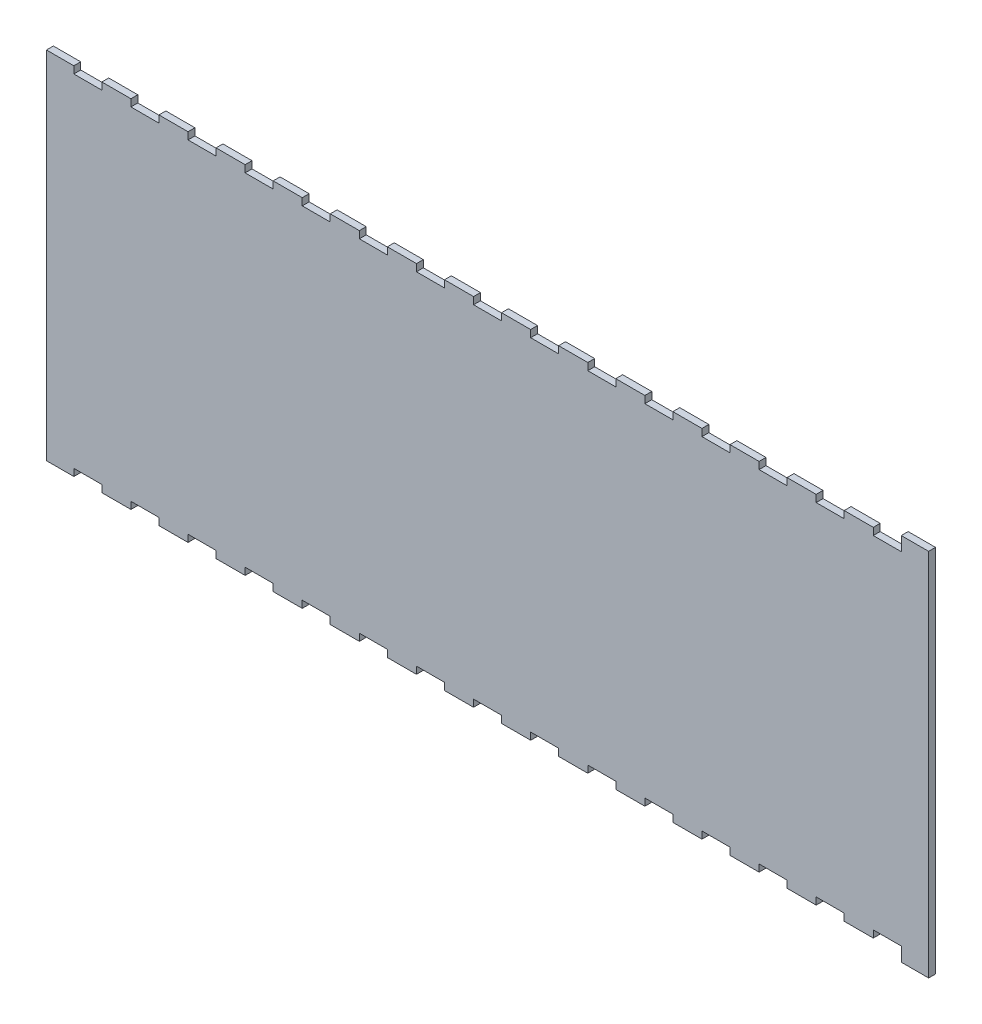
from build123d import *

# Parameters (mm, degrees)
BOSS_EXTRUDE1_DEPTH = 3.175


with BuildPart() as part:
    # Sketch1 → Boss-Extrude1 (new body)
    with BuildSketch(Plane.XY):
        Polygon((-12.6, 160.6058), (-25.5, 160.6058), (-25.5, 163.8808), (-38.907142857, 163.8808), (-38.907142857, 160.6058), (-51.807142857, 160.6058), (-51.807142857, 163.8808), (-65.214285714, 163.8808), (-65.214285714, 160.6058), (-78.114285714, 160.6058), (-78.114285714, 163.8808), (-91.521428571, 163.8808), (-91.521428571, 160.6058), (-104.421428571, 160.6058), (-104.421428571, 163.8808), (-117.828571429, 163.8808), (-117.828571429, 160.6058), (-130.728571429, 160.6058), (-130.728571429, 163.8808), (-144.135714286, 163.8808), (-144.135714286, 160.6058), (-157.035714286, 160.6058), (-157.035714286, 163.8808), (-170.442857143, 163.8808), (-170.442857143, 160.6058), (-183.342857143, 160.6058), (-183.342857143, 163.8808), (-196.75, 163.8808), (-196.75, 160.6058), (-209.65, 160.6058), (-209.65, 163.8808), (-223.057142857, 163.8808), (-223.057142857, 160.6058), (-235.957142857, 160.6058), (-235.957142857, 163.8808), (-249.364285714, 163.8808), (-249.364285714, 160.6058), (-262.264285714, 160.6058), (-262.264285714, 163.8808), (-275.671428571, 163.8808), (-275.671428571, 160.6058), (-288.571428571, 160.6058), (-288.571428571, 163.8808), (-301.978571429, 163.8808), (-301.978571429, 160.6058), (-314.878571429, 160.6058), (-314.878571429, 163.8808), (-328.285714286, 163.8808), (-328.285714286, 160.6058), (-341.185714286, 160.6058), (-341.185714286, 163.8808), (-354.592857143, 163.8808), (-354.592857143, 160.6058), (-367.492857143, 160.6058), (-367.492857143, 163.8808), (-380.9, 163.8808), (-380.9, 160.6058), (-393.8, 160.6058), (-393.8, 163.8808), (-406.4, 163.8808), (-406.4, 0), (-393.8, 0), (-393.8, 3.275), (-380.9, 3.275), (-380.9, 0), (-367.492857143, 0), (-367.492857143, 3.275), (-354.592857143, 3.275), (-354.592857143, 0), (-341.185714286, 0), (-341.185714286, 3.275), (-328.285714286, 3.275), (-328.285714286, 0), (-314.878571429, 0), (-314.878571429, 3.275), (-301.978571429, 3.275), (-301.978571429, 0), (-288.571428571, 0), (-288.571428571, 3.275), (-275.671428571, 3.275), (-275.671428571, 0), (-262.264285714, 0), (-262.264285714, 3.275), (-249.364285714, 3.275), (-249.364285714, 0), (-235.957142857, 0), (-235.957142857, 3.275), (-223.057142857, 3.275), (-223.057142857, 0), (-209.65, 0), (-209.65, 3.275), (-196.75, 3.275), (-196.75, 0), (-183.342857143, 0), (-183.342857143, 3.275), (-170.442857143, 3.275), (-170.442857143, 0), (-157.035714286, 0), (-157.035714286, 3.275), (-144.135714286, 3.275), (-144.135714286, 0), (-130.728571429, 0), (-130.728571429, 3.275), (-117.828571429, 3.275), (-117.828571429, 0), (-104.421428571, 0), (-104.421428571, 3.275), (-91.521428571, 3.275), (-91.521428571, 0), (-78.114285714, 0), (-78.114285714, 3.275), (-65.214285714, 3.275), (-65.214285714, 0), (-51.807142857, 0), (-51.807142857, 3.275), (-38.907142857, 3.275), (-38.907142857, 0), (-25.5, 0), (-25.5, 3.275), (-12.6, 3.275), (-12.6000002, -3.175), (0, -3.175), (0, 167.0558), (-12.6000002, 167.0558), align=None)
    extrude(amount=BOSS_EXTRUDE1_DEPTH)


solid = part.part
